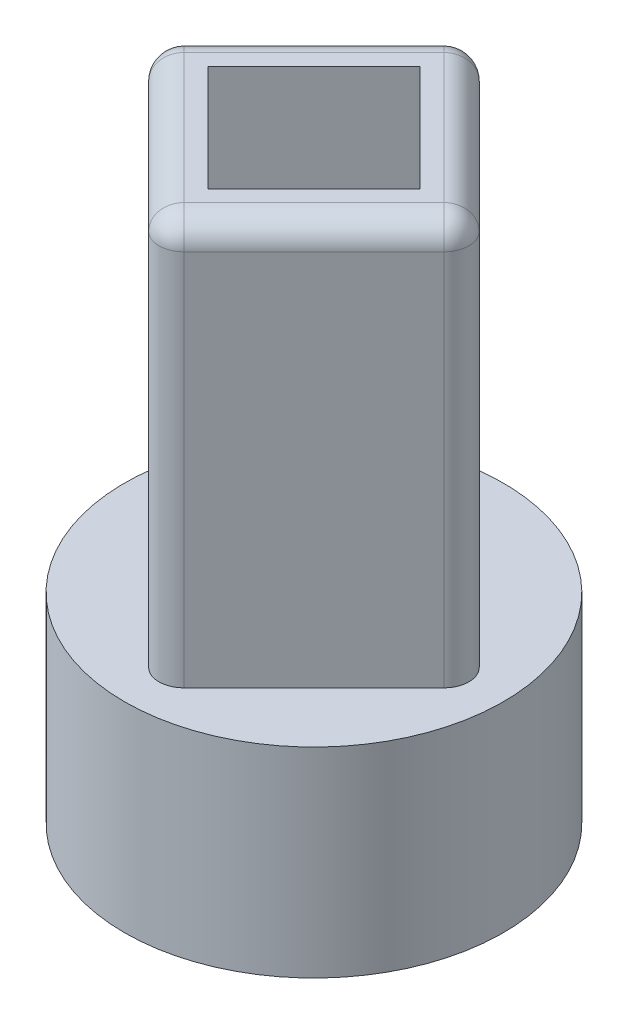
from build123d import *

# Parameters (mm, degrees)
SKETCH1_R           = 7.575
BOSS_EXTRUDE1_DEPTH = 5.2
CUT_EXTRUDE1_DEPTH  = 3.6
BOSS_EXTRUDE2_DEPTH = 18.9
FILLET1_R           = 1
BOSS_EXTRUDE3_DEPTH = 4.85
SKETCH6_R           = 1.875
BOSS_EXTRUDE4_DEPTH = 2.55
CUT_EXTRUDE2_DEPTH  = 4
SKETCH7_R           = 7.575
BOSS_EXTRUDE5_DEPTH = 2.8


with BuildPart() as part:
    # Sketch1 → Boss-Extrude1 (new body)
    with BuildSketch(Plane(origin=(0, 0, 0), x_dir=(1, 0, 0), z_dir=(0, 1, 0))):
        Circle(SKETCH1_R)
    extrude(amount=BOSS_EXTRUDE1_DEPTH)

    # Sketch2 → Cut-Extrude1 (cut)
    with BuildSketch(Plane.XZ):
        with BuildLine():
            Line((-4.359330502, -1.388114754), (0, -4.575))
            ThreePointArc((0, -4.575), (2.7, 3.693321676), (-4.359330502, -1.388114754))
        make_face()
    extrude(amount=-CUT_EXTRUDE1_DEPTH, mode=Mode.SUBTRACT)

    # Sketch4 → Boss-Extrude2 (add)
    with BuildSketch(Plane(origin=(0, 5.2, 0), x_dir=(1, 0, 0), z_dir=(0, 1, 0))):
        Polygon((6.611448404, 0), (0, 6.611448404), (-6.611448404, 0), (0, -6.611448404), align=None)
        Polygon((4.242640687, 0), (0, 4.242640687), (-4.242640687, 0), (0, -4.242640687), align=None, mode=Mode.SUBTRACT)
    extrude(amount=BOSS_EXTRUDE2_DEPTH)

    # Fillet1
    fillet1_edges = [part.edges().sort_by_distance(p)[0] for p in [
        (3.305724202, 24.1, 3.305724202),
        (3.305724202, 24.1, -3.305724202),
        (-3.305724202, 24.1, -3.305724202),
        (-3.305724202, 24.1, 3.305724202),
        (0, 14.65, 6.611448404),
        (6.611448404, 14.65, 0),
        (0, 14.65, -6.611448404),
        (-6.611448404, 14.65, 0),
    ]]
    fillet(fillet1_edges, radius=FILLET1_R)

    # Sketch5 → Boss-Extrude3 (add)
    with BuildSketch(Plane(origin=(0, 5.2, 0), x_dir=(1, 0, 0), z_dir=(0, 1, 0))):
        Polygon((0, -4.242640687), (4.242640687, 0), (0, 4.242640687), (-4.242640687, 0), align=None)
    extrude(amount=BOSS_EXTRUDE3_DEPTH)

    # Sketch6 → Boss-Extrude4 (add)
    with BuildSketch(Plane(origin=(0, 10.05, 0), x_dir=(1, 0, 0), z_dir=(0, 1, 0))):
        Circle(SKETCH6_R)
    extrude(amount=BOSS_EXTRUDE4_DEPTH)

    # Sketch3 → Cut-Extrude2 (cut)
    with BuildSketch(Plane.XZ.offset(-3.6)):
        with BuildLine():
            Line((-1.9, 2.157689737), (1.9, 2.157689737))
            ThreePointArc((1.9, 2.157689737), (0, -2.875), (-1.9, 2.157689737))
        make_face()
    extrude(amount=-CUT_EXTRUDE2_DEPTH, mode=Mode.SUBTRACT)

    # Sketch7 → Boss-Extrude5 (add)
    with BuildSketch(Plane(origin=(0, 5.2, 0), x_dir=(1, 0, 0), z_dir=(0, 1, 0))):
        Circle(SKETCH7_R)
        with BuildLine():
            Line((-5.904341623, -0.707106781), (-0.707106781, -5.904341623))
            ThreePointArc((-0.707106781, -5.904341623), (0, -6.197234842), (0.707106781, -5.904341623))
            Line((0.707106781, -5.904341623), (5.904341623, -0.707106781))
            ThreePointArc((5.904341623, -0.707106781), (6.197234842, 0), (5.904341623, 0.707106781))
            Line((5.904341623, 0.707106781), (0.707106781, 5.904341623))
            ThreePointArc((0.707106781, 5.904341623), (0, 6.197234842), (-0.707106781, 5.904341623))
            Line((-0.707106781, 5.904341623), (-5.904341623, 0.707106781))
            ThreePointArc((-5.904341623, 0.707106781), (-6.197234842, 0), (-5.904341623, -0.707106781))
        make_face(mode=Mode.SUBTRACT)
    extrude(amount=BOSS_EXTRUDE5_DEPTH)


solid = part.part
